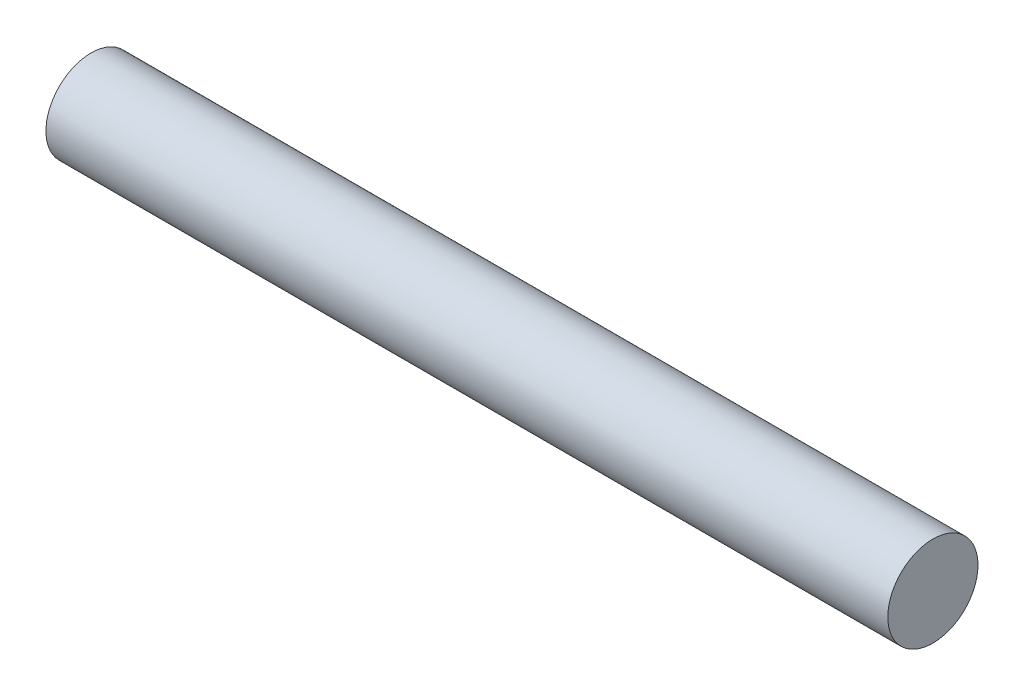
from build123d import *

# Parameters (mm, degrees)
SKETCH1_R           = 1.5
BOSS_EXTRUDE1_DEPTH = 14


with BuildPart() as part:
    # Sketch1 → Boss-Extrude1 (new body, symmetric)
    with BuildSketch(Plane(origin=(0, 0, 0), x_dir=(0, 0, -1), z_dir=(1, 0, 0))):
        Circle(SKETCH1_R)
    extrude(amount=BOSS_EXTRUDE1_DEPTH, both=True)


solid = part.part
